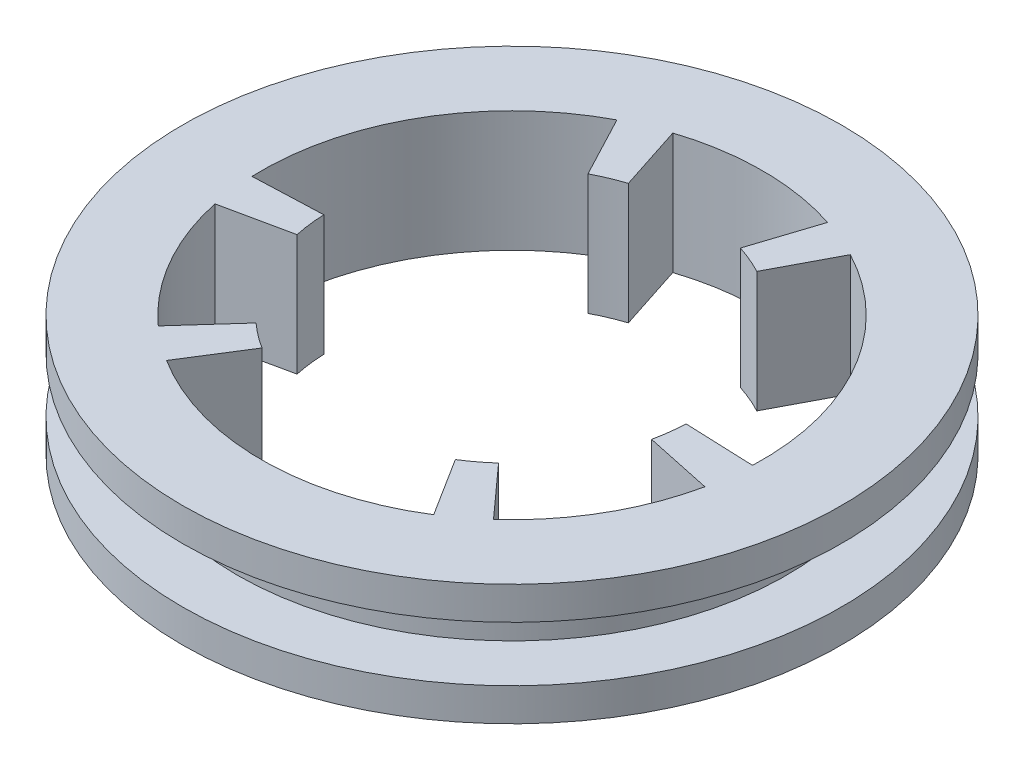
from build123d import *

# Parameters (mm, degrees)
CUT_EXTRUDE1_REACH = 13


with BuildPart() as part:
    # Sketch2 → Revolve1 (revolve)
    with BuildSketch(Plane.XY):
        Polygon((-25, 2.5), (-25, -2.5), (-30, -2.5), (-30, -5.5), (0, -5.5), (0, 5.5), (-30, 5.5), (-30, 2.5), align=None)
    revolve(axis=Axis((0, 19.987411147, 0), (0, -1, 0)))

    # Sketch3 → Cut-Extrude1 (cut, up to next)
    with BuildSketch(Plane(origin=(0, 5.5, 0), x_dir=(1, 0, 0), z_dir=(0, 1, 0)), mode=Mode.PRIVATE) as cut_extrude1_sk1:
        with BuildLine():
            ThreePointArc((15.256177825, -16.943702021), (19.745379206, -11.4), (22.301765297, -4.740386551))
            Line((22.301765297, -4.740386551), (16.139435412, -3.430542898))
            ThreePointArc((16.139435412, -3.430542898), (16.372933017, -2.043786781), (16.487498259, -0.642184674))
            Line((16.487498259, -0.642184674), (22.782724867, -0.887382459))
            ThreePointArc((22.782724867, -0.887382459), (19.745379206, 11.4), (10.622866681, 20.174109732))
            Line((10.622866681, 20.174109732), (7.687600888, 14.599684674))
            ThreePointArc((7.687600888, 14.599684674), (6.416495236, 15.201269318), (5.098780407, 15.692432519))
            Line((5.098780407, 15.692432519), (7.045587472, 21.684088572))
            ThreePointArc((7.045587472, 21.684088572), (0, 22.8), (-7.045587472, 21.684088572))
            Line((-7.045587472, 21.684088572), (-5.098780407, 15.692432519))
            ThreePointArc((-5.098780407, 15.692432519), (-6.416495236, 15.201269318), (-7.687600888, 14.599684674))
            Line((-7.687600888, 14.599684674), (-10.622866681, 20.174109732))
            ThreePointArc((-10.622866681, 20.174109732), (-19.745379206, 11.4), (-22.782724867, -0.887382459))
            Line((-22.782724867, -0.887382459), (-16.487498259, -0.642184674))
            ThreePointArc((-16.487498259, -0.642184674), (-16.372933017, -2.043786781), (-16.139435412, -3.430542898))
            Line((-16.139435412, -3.430542898), (-22.301765297, -4.740386551))
            ThreePointArc((-22.301765297, -4.740386551), (-19.745379206, -11.4), (-15.256177825, -16.943702021))
            Line((-15.256177825, -16.943702021), (-11.040655005, -12.26188962))
            ThreePointArc((-11.040655005, -12.26188962), (-9.956437781, -13.157482537), (-8.799897372, -13.9575))
            Line((-8.799897372, -13.9575), (-12.159858186, -19.286727273))
            ThreePointArc((-12.159858186, -19.286727273), (0, -22.8), (12.159858186, -19.286727273))
            Line((12.159858186, -19.286727273), (8.799897372, -13.9575))
            ThreePointArc((8.799897372, -13.9575), (9.956437781, -13.157482537), (11.040655005, -12.26188962))
            Line((11.040655005, -12.26188962), (15.256177825, -16.943702021))
        make_face()
    cut_extrude1_tool1 = extrude(cut_extrude1_sk1.sketch, amount=-CUT_EXTRUDE1_REACH, mode=Mode.PRIVATE) & part.part
    add(cut_extrude1_tool1.solids().sort_by_distance((0, 5.5, 0))[0], mode=Mode.SUBTRACT)


solid = part.part
